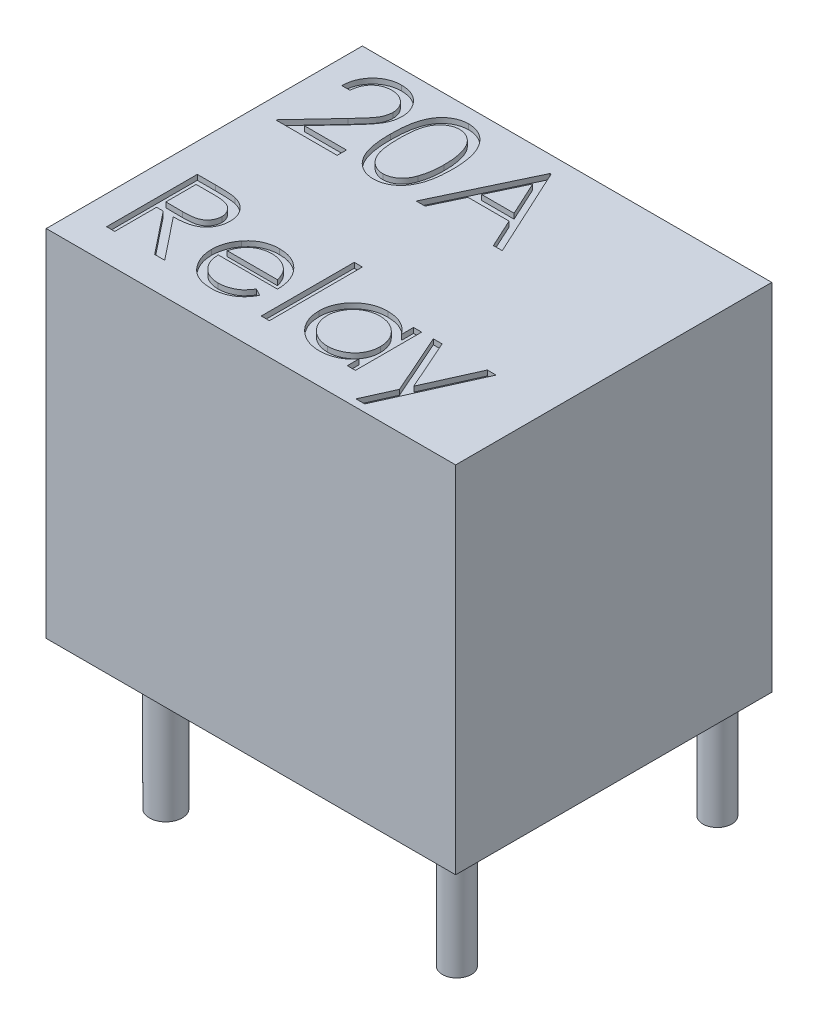
from build123d import *

# Parameters (mm, degrees)
SKETCH1_W           = 15.8
SKETCH1_H           = 12.2
BOSS_EXTRUDE1_DEPTH = 13.7
SKETCH2_W           = 0.314102564
SKETCH2_H           = 3.58974359
CUT_EXTRUDE1_DEPTH  = 0.2
SKETCH3_R           = 0.561179854
SKETCH3_R_2         = 0.557721781
SKETCH3_R_3         = 0.672705982
SKETCH3_R_4         = 0.631160772
SKETCH3_R_5         = 0.616326893
BOSS_EXTRUDE2_DEPTH = 4.2
SKETCH4_W           = 0.531781233
SKETCH4_H           = 8.404737531
BOSS_EXTRUDE3_DEPTH = 0.2


with BuildPart() as part:
    # Sketch1 → Boss-Extrude1 (new body)
    with BuildSketch(Plane(origin=(0, 0, 0), x_dir=(1, 0, 0), z_dir=(0, 1, 0))):
        with Locations((2.206117021, -2.696276596)):
            Rectangle(SKETCH1_W, SKETCH1_H)
    extrude(amount=BOSS_EXTRUDE1_DEPTH)

    # Sketch2 → Cut-Extrude1 (cut)
    with BuildSketch(Plane(origin=(0, 13.7, 0), x_dir=(1, 0, 0), z_dir=(0, 1, 0))):
        with BuildLine():
            Line((-4.454447656, 1.685311696), (-4.76855022, 1.685311696))
            add(Edge.make_bspline(
                [(-4.76855022, 1.685311696), (-4.766503067, 1.726982584), (-4.762482513, 1.808823099), (-4.743654224, 1.928147005), (-4.716713346, 2.042201804), (-4.678621892, 2.150071718), (-4.631315615, 2.252710525), (-4.574585587, 2.349710541), (-4.507391737, 2.440701729), (-4.431185003, 2.524840573), (-4.348416364, 2.602028143), (-4.259110424, 2.668683386), (-4.165265397, 2.725001058), (-4.067165998, 2.772082299), (-3.963705434, 2.807422145), (-3.855822576, 2.833643785), (-3.74304344, 2.849420131), (-3.666203418, 2.851115916), (-3.627123938, 2.851978363)],
                knots=[0, 0, 0, 0, 0.000125083, 0.00024566, 0.000361805, 0.000476223, 0.000588214, 0.000700404, 0.000812728, 0.00092691, 0.001040529, 0.001151727, 0.001260545, 0.001368429, 0.001477521, 0.001587884, 0.001701119, 0.00181831, 0.00181831, 0.00181831, 0.00181831], degree=3))
            add(Edge.make_bspline(
                [(-3.627123938, 2.851978363), (-3.588745864, 2.851079907), (-3.513334319, 2.849314472), (-3.403272305, 2.834153442), (-3.29849501, 2.810407851), (-3.199207244, 2.777092434), (-3.106201179, 2.732308007), (-3.018778135, 2.678510468), (-2.935897324, 2.616290637), (-2.86129054, 2.543036824), (-2.792782461, 2.464834439), (-2.733680206, 2.381346536), (-2.683067042, 2.29511725), (-2.640879362, 2.205489048), (-2.609823223, 2.11161802), (-2.586245015, 2.014870817), (-2.572917602, 1.914246006), (-2.570872178, 1.84613945), (-2.569832271, 1.811513619)],
                knots=[0, 0, 0, 0, 0.000115089, 0.000226145, 0.000332614, 0.000437044, 0.000539592, 0.000641561, 0.000744629, 0.00084975, 0.000954621, 0.001056175, 0.001156101, 0.001254284, 0.001352726, 0.001452208, 0.001552655, 0.001656537, 0.001656537, 0.001656537, 0.001656537], degree=3))
            add(Edge.make_bspline(
                [(-2.569832271, 1.811513619), (-2.571525534, 1.762765785), (-2.574882345, 1.666125571), (-2.603596722, 1.524110708), (-2.648443233, 1.386517289), (-2.70244059, 1.275779987), (-2.756913034, 1.186546493), (-2.806000542, 1.113077789), (-2.863465353, 1.03397232), (-2.930143851, 0.949494983), (-3.004656723, 0.858984078), (-3.087678886, 0.762494282), (-3.179802368, 0.661022512), (-3.244460869, 0.591716911), (-3.277965284, 0.555804485)],
                knots=[0, 0, 0, 0, 0.000146118, 0.000289672, 0.0004329, 0.00057934, 0.000657978, 0.000746456, 0.000844345, 0.000951219, 0.001069268, 0.00119604, 0.001333047, 0.001480391, 0.001480391, 0.001480391, 0.001480391], degree=3))
            Line((-3.277965284, 0.555804485), (-4.153666406, -0.378790868))
            Line((-4.153666406, -0.378790868), (-2.524960476, -0.378790868))
            Line((-2.524960476, -0.378790868), (-2.524960476, -0.737765227))
            Line((-2.524960476, -0.737765227), (-4.903165604, -0.737765227))
            Line((-4.903165604, -0.737765227), (-3.54579381, 0.710752401))
            add(Edge.make_bspline(
                [(-3.54579381, 0.710752401), (-3.512745923, 0.745250708), (-3.449267696, 0.811514895), (-3.359485119, 0.908257855), (-3.278846131, 0.998007395), (-3.206828738, 1.080593944), (-3.144995232, 1.157225512), (-3.090123, 1.225420215), (-3.046157409, 1.288174666), (-2.998442014, 1.36091528), (-2.952228032, 1.449727597), (-2.912515676, 1.558261286), (-2.888300828, 1.669988539), (-2.885395992, 1.745490576), (-2.883934835, 1.783468748)],
                knots=[0, 0, 0, 0, 0.000143319, 0.000275286, 0.00039593, 0.000505287, 0.000603949, 0.000691331, 0.000767782, 0.00083371, 0.000952247, 0.001067137, 0.001179618, 0.001293462, 0.001293462, 0.001293462, 0.001293462], degree=3))
            add(Edge.make_bspline(
                [(-2.883934835, 1.783468748), (-2.884570578, 1.807350146), (-2.885823504, 1.854415796), (-2.896881201, 1.923421555), (-2.913591707, 1.989986369), (-2.937536965, 2.054314988), (-2.969143705, 2.11576064), (-3.007617085, 2.174398121), (-3.052007149, 2.231087086), (-3.103358418, 2.284240384), (-3.159769938, 2.332921589), (-3.219364187, 2.376045675), (-3.282414292, 2.412084786), (-3.348654414, 2.441628283), (-3.417899883, 2.464803664), (-3.490284628, 2.480862243), (-3.565608645, 2.490944727), (-3.61704214, 2.492308899), (-3.643249739, 2.493004004)],
                knots=[0, 0, 0, 0, 7.16e-05, 0.00014111, 0.00020913, 0.00027724, 0.000346538, 0.000415963, 0.000487357, 0.000562233, 0.000637292, 0.000710646, 0.000782564, 0.000854749, 0.000927915, 0.001001225, 0.001076884, 0.001155488, 0.001155488, 0.001155488, 0.001155488], degree=3))
            add(Edge.make_bspline(
                [(-3.643249739, 2.493004004), (-3.670620572, 2.492288972), (-3.724372368, 2.490884766), (-3.803291401, 2.481062102), (-3.878577179, 2.464116262), (-3.950419081, 2.440939588), (-4.018938667, 2.411481039), (-4.083802711, 2.374789294), (-4.144865601, 2.331005801), (-4.202242124, 2.281365245), (-4.255106103, 2.226097643), (-4.301552979, 2.16448768), (-4.342136993, 2.097660265), (-4.377546226, 2.025795714), (-4.406301917, 1.948241934), (-4.428275067, 1.86527423), (-4.445661914, 1.777252848), (-4.451470434, 1.716467763), (-4.454447656, 1.685311696)],
                knots=[0, 0, 0, 0, 8.2106e-05, 0.000161243, 0.000238127, 0.000313291, 0.000387401, 0.000461495, 0.000536397, 0.000612445, 0.000688819, 0.000765383, 0.000843422, 0.000923066, 0.001005373, 0.001091093, 0.001180334, 0.001274175, 0.001274175, 0.001274175, 0.001274175], degree=3))
        make_face()
        with BuildLine():
            add(Edge.make_bspline(
                [(-2.210857912, 1.01083253), (-2.210529894, 1.066929917), (-2.209892714, 1.175899902), (-2.202804293, 1.334684544), (-2.191028951, 1.483644833), (-2.174891578, 1.622787899), (-2.155253598, 1.752149663), (-2.129038111, 1.87138442), (-2.099225308, 1.981044027), (-2.064672863, 2.081486075), (-2.025685074, 2.174063778), (-1.983250813, 2.26048898), (-1.935686018, 2.340630912), (-1.885709106, 2.415768703), (-1.831297034, 2.484672397), (-1.773998243, 2.54831506), (-1.711576367, 2.60522581), (-1.646153359, 2.657072113), (-1.577136895, 2.702521584), (-1.506494228, 2.742554323), (-1.433739123, 2.77675419), (-1.35867294, 2.803644626), (-1.281970382, 2.825855473), (-1.203363315, 2.841044421), (-1.122721951, 2.850601329), (-1.068290516, 2.851514997), (-1.040685637, 2.851978363)],
                knots=[0, 0, 0, 0, 0.000168282, 0.000326891, 0.000476705, 0.00061646, 0.000747059, 0.00086904, 0.000982494, 0.001087814, 0.001187428, 0.001283689, 0.001376399, 0.001466822, 0.001554203, 0.001639568, 0.001723424, 0.001807301, 0.001889751, 0.001971063, 0.002050735, 0.002130583, 0.002210036, 0.002290062, 0.002370508, 0.002453288, 0.002453288, 0.002453288, 0.002453288], degree=3))
            add(Edge.make_bspline(
                [(-1.040685637, 2.851978363), (-1.012850158, 2.851490548), (-0.957494149, 2.850520437), (-0.875653774, 2.841196494), (-0.795704092, 2.825725371), (-0.717985953, 2.803804397), (-0.641860967, 2.77660872), (-0.567924559, 2.742521603), (-0.495717478, 2.702842736), (-0.42638719, 2.656218858), (-0.359172575, 2.604236582), (-0.295724612, 2.545473913), (-0.236037526, 2.480524194), (-0.179362221, 2.41008233), (-0.127306623, 2.332797245), (-0.077733191, 2.250013135), (-0.033361155, 2.160282271), (0.00937352, 2.065101803), (0.046260507, 1.961838144), (0.079526752, 1.851073383), (0.10640572, 1.731499197), (0.128794993, 1.603742951), (0.146139889, 1.467335468), (0.158772531, 1.322569153), (0.165445616, 1.169348762), (0.166702317, 1.064590913), (0.167347216, 1.01083253)],
                knots=[0, 0, 0, 0, 8.3481e-05, 0.000166017, 0.000246731, 0.000327534, 0.000408041, 0.000488986, 0.000571522, 0.000654944, 0.000739373, 0.000826202, 0.000914021, 0.001003809, 0.001097153, 0.001193347, 0.001293057, 0.001397277, 0.001506176, 0.001621751, 0.001744038, 0.001873599, 0.002010742, 0.002156422, 0.002309427, 0.002470709, 0.002470709, 0.002470709, 0.002470709], degree=3))
            add(Edge.make_bspline(
                [(0.167347216, 1.01083253), (0.166695631, 0.957308622), (0.165426046, 0.85301947), (0.158847339, 0.700488495), (0.145888708, 0.556490451), (0.129678719, 0.420679989), (0.107227756, 0.29362237), (0.07962259, 0.174877921), (0.048972267, 0.06393385), (0.011137473, -0.038300962), (-0.030273237, -0.133252685), (-0.075328433, -0.221919833), (-0.123598259, -0.305086126), (-0.176187004, -0.382085873), (-0.232240418, -0.45346453), (-0.292958206, -0.517962152), (-0.356628792, -0.577132824), (-0.424041207, -0.629784452), (-0.494452759, -0.675869256), (-0.566411836, -0.717083107), (-0.641195219, -0.750315802), (-0.717108172, -0.778850843), (-0.795236538, -0.800651295), (-0.875482928, -0.81572515), (-0.957439164, -0.826296999), (-1.012840729, -0.827103479), (-1.040685637, -0.827508817)],
                knots=[0, 0, 0, 0, 0.000160581, 0.000312886, 0.000457868, 0.000594226, 0.000723097, 0.000844701, 0.000959884, 0.001068125, 0.001171421, 0.001270505, 0.001366343, 0.001459687, 0.001550023, 0.00163832, 0.001725149, 0.001810562, 0.001894568, 0.001977446, 0.00205903, 0.002139777, 0.00222058, 0.002301983, 0.002384599, 0.00246808, 0.00246808, 0.00246808, 0.00246808], degree=3))
            add(Edge.make_bspline(
                [(-1.040685637, -0.827508817), (-1.068289751, -0.827042461), (-1.122719675, -0.826122899), (-1.203372101, -0.816609168), (-1.281654544, -0.801313664), (-1.357953298, -0.77989706), (-1.432659813, -0.753682224), (-1.5047561, -0.71952854), (-1.575043784, -0.680194471), (-1.64333534, -0.63539905), (-1.708347501, -0.584077367), (-1.770446106, -0.527313078), (-1.828071125, -0.463689667), (-1.881705221, -0.394211744), (-1.932679309, -0.319518501), (-1.979568682, -0.238590128), (-2.022939536, -0.151747518), (-2.062583027, -0.058429607), (-2.09773169, 0.042725321), (-2.128779399, 0.152874499), (-2.153293556, 0.272990135), (-2.174276511, 0.402107502), (-2.191200894, 0.540781433), (-2.20275522, 0.689087211), (-2.209896535, 0.84693242), (-2.210531605, 0.955202194), (-2.210857912, 1.01083253)],
                knots=[0, 0, 0, 0, 8.278e-05, 0.000163226, 0.000243252, 0.00032184, 0.00040079, 0.000480463, 0.00056082, 0.000642298, 0.000725191, 0.000809047, 0.000894412, 0.000982346, 0.001072188, 0.001165503, 0.001262704, 0.001363236, 0.001469448, 0.001583766, 0.001706286, 0.001836995, 0.001976138, 0.002125253, 0.002283161, 0.002450041, 0.002450041, 0.002450041, 0.002450041], degree=3))
        make_face()
        with BuildLine():
            add(Edge.make_bspline(
                [(-1.896755348, 1.012234773), (-1.896635901, 0.965486074), (-1.896404078, 0.87475603), (-1.890347877, 0.742912769), (-1.882097645, 0.61994244), (-1.871456348, 0.505688903), (-1.855653399, 0.400538891), (-1.837946612, 0.303769208), (-1.816398522, 0.215891971), (-1.790903504, 0.13630416), (-1.761864407, 0.063655091), (-1.730158544, -0.003946124), (-1.696097821, -0.06729806), (-1.65797867, -0.125831668), (-1.616463607, -0.179737833), (-1.572490348, -0.229970665), (-1.524417763, -0.274767646), (-1.457914021, -0.328494501), (-1.370117547, -0.384013635), (-1.259497091, -0.432359725), (-1.14582864, -0.462742181), (-1.06867739, -0.466605937), (-1.03016881, -0.468534458)],
                knots=[0, 0, 0, 0, 0.000140231, 0.000272162, 0.000395845, 0.00050998, 0.000616273, 0.00071473, 0.000805025, 0.000887508, 0.000965234, 0.00103957, 0.001111417, 0.001180842, 0.001248855, 0.001315406, 0.001380877, 0.0014457, 0.001571746, 0.00169106, 0.001806864, 0.001922266, 0.001922266, 0.001922266, 0.001922266], degree=3))
            add(Edge.make_bspline(
                [(-1.03016881, -0.468534458), (-0.991411138, -0.466936677), (-0.913975815, -0.463744414), (-0.80084202, -0.432945677), (-0.69101175, -0.386476137), (-0.604939809, -0.331528632), (-0.539457266, -0.279200302), (-0.492540276, -0.234585654), (-0.449478227, -0.184629787), (-0.408636152, -0.130730491), (-0.371177077, -0.071858007), (-0.337113939, -0.008295431), (-0.306030591, 0.060133747), (-0.288321546, 0.107903486), (-0.279267367, 0.132326921)],
                knots=[0, 0, 0, 0, 0.000116044, 0.000231848, 0.000349318, 0.000472837, 0.000536674, 0.000600645, 0.000666733, 0.000734322, 0.000803367, 0.000875831, 0.000950509, 0.001028633, 0.001028633, 0.001028633, 0.001028633], degree=3))
            add(Edge.make_bspline(
                [(-0.279267367, 0.132326921), (-0.2687156, 0.16355666), (-0.247290986, 0.226966424), (-0.219679211, 0.325330076), (-0.197933812, 0.42853284), (-0.178370446, 0.535957957), (-0.165017391, 0.648397658), (-0.154269577, 0.765504042), (-0.14793889, 0.887365404), (-0.147154139, 0.970160395), (-0.146755348, 1.012234773)],
                knots=[0, 0, 0, 0, 9.8886e-05, 0.00020078, 0.000306259, 0.000415188, 0.00052824, 0.000645799, 0.000767957, 0.000894177, 0.000894177, 0.000894177, 0.000894177], degree=3))
            add(Edge.make_bspline(
                [(-0.146755348, 1.012234773), (-0.147305537, 1.054302346), (-0.148381825, 1.136595511), (-0.152495813, 1.257113691), (-0.163119387, 1.371581452), (-0.174918506, 1.480491925), (-0.192315727, 1.583242227), (-0.211073534, 1.680692533), (-0.236274746, 1.771635558), (-0.263194521, 1.857495139), (-0.294004917, 1.937295794), (-0.327920651, 2.01140958), (-0.36414241, 2.080194305), (-0.40348465, 2.143461246), (-0.445480333, 2.201493789), (-0.491237883, 2.253128384), (-0.538942255, 2.299965352), (-0.605759441, 2.353427921), (-0.693233731, 2.407939617), (-0.802079378, 2.458105376), (-0.915350023, 2.486913669), (-0.991923477, 2.490975356), (-1.03016881, 2.493004004)],
                knots=[0, 0, 0, 0, 0.000126219, 0.000246912, 0.000361616, 0.00047102, 0.00057545, 0.000674176, 0.000768567, 0.000858368, 0.000944043, 0.001024988, 0.001102772, 0.001177091, 0.00124833, 0.001317386, 0.001383826, 0.001448649, 0.001573728, 0.001692043, 0.001806995, 0.001921698, 0.001921698, 0.001921698, 0.001921698], degree=3))
            add(Edge.make_bspline(
                [(-1.03016881, 2.493004004), (-1.068879402, 2.490972557), (-1.146371107, 2.486905963), (-1.260819062, 2.45821271), (-1.370523414, 2.408199744), (-1.457766388, 2.353247371), (-1.524630175, 2.30090906), (-1.571712868, 2.255522606), (-1.61585904, 2.205876351), (-1.656526741, 2.151474437), (-1.694616024, 2.093009069), (-1.729597036, 2.030020304), (-1.761114366, 1.96218894), (-1.790198902, 1.889572505), (-1.81577169, 1.80999156), (-1.836865653, 1.722222567), (-1.856352707, 1.625760675), (-1.870147975, 1.520041167), (-1.882411731, 1.405759014), (-1.890293079, 1.282481695), (-1.896424337, 1.150417315), (-1.896642801, 1.059218157), (-1.896755348, 1.012234773)],
                knots=[0, 0, 0, 0, 0.000116101, 0.000232413, 0.000351368, 0.000476447, 0.000540832, 0.000605795, 0.000672346, 0.000739935, 0.00080936, 0.000881545, 0.00095588, 0.001033607, 0.001116089, 0.001206384, 0.001304286, 0.001411174, 0.001526077, 0.001649061, 0.001781692, 0.001922624, 0.001922624, 0.001922624, 0.001922624], degree=3))
        make_face(mode=Mode.SUBTRACT)
        Polygon((2.23144978, 2.762234773), (3.846834396, -0.737765227), (3.505388081, -0.737765227), (2.987960197, 0.384029645), (1.401321575, 0.384029645), (0.869170133, -0.737765227), (0.526321575, -0.737765227), (2.186577985, 2.762234773), align=None)
        Polygon((2.205508274, 2.080043267), (1.571694171, 0.743004004), (2.822495453, 0.743004004), align=None, mode=Mode.SUBTRACT)
        with BuildLine():
            Line((-4.58906304, -4.07109856), (-3.888642367, -4.07109856))
            add(Edge.make_bspline(
                [(-3.888642367, -4.07109856), (-3.841901239, -4.071254146), (-3.752153094, -4.071552888), (-3.623579824, -4.073218651), (-3.506752727, -4.077993007), (-3.401732888, -4.082101591), (-3.308522233, -4.089593532), (-3.226834942, -4.096754179), (-3.157047244, -4.10612784), (-3.114801393, -4.114833263), (-3.095673617, -4.118774842)],
                knots=[0, 0, 0, 0, 0.000140226, 0.00026925, 0.000385712, 0.000490995, 0.000584507, 0.000666202, 0.000736998, 0.000795574, 0.000795574, 0.000795574, 0.000795574], degree=3))
            add(Edge.make_bspline(
                [(-3.095673617, -4.118774842), (-3.070066993, -4.125101608), (-3.019400004, -4.137620171), (-2.946449938, -4.164079772), (-2.876935614, -4.194699397), (-2.811145789, -4.230663117), (-2.749409998, -4.272237897), (-2.691091687, -4.318706019), (-2.635926224, -4.369813225), (-2.586144594, -4.426848066), (-2.539205542, -4.486684576), (-2.499616916, -4.551388333), (-2.465490436, -4.61904986), (-2.438319919, -4.690357278), (-2.416441945, -4.76461905), (-2.401015706, -4.842507847), (-2.391764518, -4.923668822), (-2.390822663, -4.979026731), (-2.390345092, -5.007096156)],
                knots=[0, 0, 0, 0, 7.9081e-05, 0.000156475, 0.000232432, 0.000306798, 0.00038108, 0.000455429, 0.000530331, 0.000606314, 0.000682321, 0.000758201, 0.000833453, 0.000909362, 0.000986794, 0.001065445, 0.001147284, 0.001231465, 0.001231465, 0.001231465, 0.001231465], degree=3))
            add(Edge.make_bspline(
                [(-2.390345092, -5.007096156), (-2.39181409, -5.053731261), (-2.394680486, -5.144728429), (-2.421405589, -5.27678931), (-2.465182109, -5.399978625), (-2.525505398, -5.514141263), (-2.602324874, -5.617051908), (-2.694649665, -5.707442363), (-2.802531276, -5.783082276), (-2.902960592, -5.835535081), (-2.991674792, -5.869127989), (-3.064708105, -5.892764348), (-3.144375082, -5.911026313), (-3.229912417, -5.927386445), (-3.321676072, -5.93973814), (-3.419446112, -5.948784734), (-3.523292263, -5.954438783), (-3.594631333, -5.955280788), (-3.631330669, -5.955713945)],
                knots=[0, 0, 0, 0, 0.000139777, 0.000272741, 0.000402249, 0.000530843, 0.000658588, 0.000786009, 0.000916741, 0.001052522, 0.001124656, 0.001201155, 0.001282612, 0.001369656, 0.001462366, 0.001560247, 0.001664165, 0.001774261, 0.001774261, 0.001774261, 0.001774261], degree=3))
            Line((-3.631330669, -5.955713945), (-2.345473297, -7.57109856))
            Line((-2.345473297, -7.57109856), (-2.733894771, -7.57109856))
            Line((-2.733894771, -7.57109856), (-4.019752143, -5.955713945))
            Line((-4.019752143, -5.955713945), (-4.274960476, -5.955713945))
            Line((-4.274960476, -5.955713945), (-4.274960476, -7.57109856))
            Line((-4.274960476, -7.57109856), (-4.58906304, -7.57109856))
            Line((-4.58906304, -7.57109856), (-4.58906304, -4.07109856))
        make_face()
        with BuildLine():
            Line((-4.274960476, -4.430072919), (-4.274960476, -5.596739586))
            Line((-4.274960476, -5.596739586), (-3.634135156, -5.601647438))
            add(Edge.make_bspline(
                [(-3.634135156, -5.601647438), (-3.604215117, -5.601660675), (-3.54622156, -5.601686331), (-3.462320895, -5.597692555), (-3.384200783, -5.593149237), (-3.312160031, -5.586199891), (-3.246166456, -5.57724382), (-3.186253043, -5.566040835), (-3.132321991, -5.552988773), (-3.069423452, -5.532787147), (-2.999186921, -5.500781129), (-2.922855461, -5.45421563), (-2.857853123, -5.395646511), (-2.802935261, -5.328673055), (-2.758805829, -5.255036806), (-2.727693775, -5.175620437), (-2.707951333, -5.092428839), (-2.705622787, -5.035250731), (-2.704447656, -5.006395034)],
                knots=[0, 0, 0, 0, 8.9746e-05, 0.000173954, 0.000251933, 0.000324488, 0.000391021, 0.000451663, 0.000507268, 0.000557378, 0.000649639, 0.000738152, 0.000824558, 0.000910739, 0.000997194, 0.001080909, 0.00116578, 0.001252248, 0.001252248, 0.001252248, 0.001252248], degree=3))
            add(Edge.make_bspline(
                [(-2.704447656, -5.006395034), (-2.705649777, -4.978248461), (-2.708031942, -4.922472222), (-2.727480711, -4.840816312), (-2.760370092, -4.763749362), (-2.80469233, -4.691584877), (-2.858691485, -4.626079141), (-2.922009298, -4.570031988), (-2.992914493, -4.523782523), (-3.059185691, -4.494228143), (-3.118419904, -4.476108289), (-3.169849564, -4.463357125), (-3.227961041, -4.453112657), (-3.2930365, -4.444904596), (-3.364798131, -4.437849651), (-3.443608782, -4.433097873), (-3.528945562, -4.430284009), (-3.588092493, -4.43014492), (-3.618710476, -4.430072919)],
                knots=[0, 0, 0, 0, 8.4371e-05, 0.000167192, 0.000250141, 0.000334794, 0.000420435, 0.000503871, 0.000587493, 0.000673488, 0.0007205, 0.000773215, 0.000832351, 0.0008974, 0.000969955, 0.001048634, 0.001134217, 0.001226067, 0.001226067, 0.001226067, 0.001226067], degree=3))
            Line((-3.618710476, -4.430072919), (-4.274960476, -4.430072919))
        make_face(mode=Mode.SUBTRACT)
        with BuildLine():
            Line((0.381890485, -6.763406252), (0.66093696, -6.909940708))
            add(Edge.make_bspline(
                [(0.66093696, -6.909940708), (0.638700364, -6.949384039), (0.595436756, -7.026125142), (0.521036008, -7.131557002), (0.443043935, -7.226404718), (0.357939967, -7.308134372), (0.268270288, -7.379385757), (0.173537634, -7.441723582), (0.073248816, -7.494842102), (-0.032600909, -7.53959463), (-0.14490046, -7.574004124), (-0.263921976, -7.598308345), (-0.389893472, -7.613331614), (-0.476239652, -7.615076755), (-0.520453265, -7.615970355)],
                knots=[0, 0, 0, 0, 0.000135759, 0.000264133, 0.000386579, 0.000503597, 0.000617365, 0.000729763, 0.000843304, 0.000957371, 0.001074023, 0.001195027, 0.001321389, 0.001453992, 0.001453992, 0.001453992, 0.001453992], degree=3))
            add(Edge.make_bspline(
                [(-0.520453265, -7.615970355), (-0.569595242, -7.61482318), (-0.665457004, -7.612585373), (-0.804996751, -7.593292908), (-0.936376169, -7.56182055), (-1.059587873, -7.517855008), (-1.174330125, -7.460427684), (-1.28083098, -7.390468202), (-1.379650506, -7.308335948), (-1.467674715, -7.213319504), (-1.546918598, -7.111637547), (-1.616844418, -7.005681662), (-1.675301849, -6.895718438), (-1.722854459, -6.782447914), (-1.761259324, -6.66658402), (-1.788026028, -6.547072553), (-1.803455776, -6.424236969), (-1.805820221, -6.341139633), (-1.807011758, -6.299263624)],
                knots=[0, 0, 0, 0, 0.000147371, 0.000287478, 0.000421649, 0.000552053, 0.000679042, 0.000805636, 0.000933558, 0.00106351, 0.001193382, 0.001319977, 0.001443869, 0.001566405, 0.001688128, 0.001809576, 0.001933238, 0.002058864, 0.002058864, 0.002058864, 0.002058864], degree=3))
            add(Edge.make_bspline(
                [(-1.807011758, -6.299263624), (-1.805952617, -6.259968794), (-1.803853539, -6.182091629), (-1.790622751, -6.066826085), (-1.767174458, -5.954797632), (-1.734998134, -5.845913184), (-1.693446888, -5.74035505), (-1.642614669, -5.638058986), (-1.582422291, -5.539133847), (-1.535949617, -5.476730713), (-1.512540604, -5.445297278)],
                knots=[0, 0, 0, 0, 0.000117891, 0.000233644, 0.000347498, 0.000460856, 0.000573868, 0.000687374, 0.000803169, 0.000920699, 0.000920699, 0.000920699, 0.000920699], degree=3))
            add(Edge.make_bspline(
                [(-1.512540604, -5.445297278), (-1.480832922, -5.407428408), (-1.418421975, -5.332890258), (-1.31286562, -5.234951932), (-1.198565423, -5.152908157), (-1.076953797, -5.08490102), (-0.946617323, -5.033227373), (-0.809308032, -4.994719791), (-0.663462446, -4.97314178), (-0.563757225, -4.970093947), (-0.512740925, -4.968534458)],
                knots=[0, 0, 0, 0, 0.000148071, 0.000291452, 0.00043058, 0.000569298, 0.000708346, 0.00085021, 0.000996268, 0.001149307, 0.001149307, 0.001149307, 0.001149307], degree=3))
            add(Edge.make_bspline(
                [(-0.512740925, -4.968534458), (-0.46029332, -4.969888506), (-0.357403074, -4.972544842), (-0.207370953, -4.997171175), (-0.065410236, -5.03622373), (0.068422268, -5.09137752), (0.194140129, -5.162537072), (0.310926178, -5.250678913), (0.420777691, -5.353097001), (0.48468627, -5.43186021), (0.517206992, -5.471939906)],
                knots=[0, 0, 0, 0, 0.000157241, 0.00030847, 0.000454763, 0.000598116, 0.000741606, 0.000886879, 0.001036172, 0.001190853, 0.001190853, 0.001190853, 0.001190853], degree=3))
            add(Edge.make_bspline(
                [(0.517206992, -5.471939906), (0.53933393, -5.502143488), (0.583440523, -5.562349606), (0.638687623, -5.660520763), (0.686645018, -5.763231358), (0.724977979, -5.872141655), (0.75601748, -5.985961235), (0.778474299, -6.10550378), (0.791643918, -6.230733691), (0.794232615, -6.316060247), (0.795552344, -6.359560099)],
                knots=[0, 0, 0, 0, 0.000112234, 0.000223721, 0.000337279, 0.000451932, 0.000569628, 0.000690912, 0.000816421, 0.00094695, 0.00094695, 0.00094695, 0.00094695], degree=3))
            Line((0.795552344, -6.359560099), (-1.492909194, -6.359560099))
            add(Edge.make_bspline(
                [(-1.492909194, -6.359560099), (-1.491369588, -6.393260563), (-1.488342014, -6.459531167), (-1.474226871, -6.55650195), (-1.451978097, -6.648875292), (-1.420709034, -6.735958334), (-1.382842189, -6.818888461), (-1.336456472, -6.897050498), (-1.281116918, -6.970088428), (-1.219391219, -7.038655566), (-1.150684124, -7.099716327), (-1.078401376, -7.154368103), (-1.001507811, -7.2001737), (-0.920609728, -7.23735359), (-0.835837943, -7.266459906), (-0.747165748, -7.286327727), (-0.654767631, -7.299634833), (-0.591781897, -7.301114499), (-0.559716085, -7.301867791)],
                knots=[0, 0, 0, 0, 0.000101159, 0.000198924, 0.000293472, 0.000385722, 0.000476069, 0.000566611, 0.000657757, 0.000750573, 0.000842919, 0.000933083, 0.001022062, 0.001110842, 0.001199752, 0.001290403, 0.001383113, 0.001479259, 0.001479259, 0.001479259, 0.001479259], degree=3))
            add(Edge.make_bspline(
                [(-0.559716085, -7.301867791), (-0.528364938, -7.301259734), (-0.466158247, -7.300053233), (-0.373517389, -7.288321322), (-0.282377862, -7.269351047), (-0.193116879, -7.243461057), (-0.107546033, -7.211884204), (-0.028300483, -7.173781347), (0.044579733, -7.1316316), (0.112696699, -7.083421925), (0.178767693, -7.024413738), (0.244310179, -6.950778017), (0.314586833, -6.863690489), (0.358576425, -6.798144823), (0.381890485, -6.763406252)],
                knots=[0, 0, 0, 0, 9.4016e-05, 0.000186545, 0.000279636, 0.000373054, 0.000465125, 0.000552934, 0.000636508, 0.000717442, 0.000802858, 0.000901616, 0.001012865, 0.001138311, 0.001138311, 0.001138311, 0.001138311], degree=3))
        make_face()
        with BuildLine():
            add(Edge.make_bspline(
                [(0.48144978, -6.045457534), (0.469953156, -6.003794661), (0.447825854, -5.92360704), (0.40158949, -5.81256615), (0.349517949, -5.713878249), (0.287896218, -5.628298616), (0.218077492, -5.552295103), (0.137432309, -5.485876518), (0.046996416, -5.426459066), (-0.052762725, -5.376306567), (-0.15840451, -5.333616708), (-0.269010702, -5.304991593), (-0.38186849, -5.28538205), (-0.458202776, -5.283555942), (-0.496615124, -5.282637022)],
                knots=[0, 0, 0, 0, 0.000129543, 0.000249328, 0.000360065, 0.000463575, 0.000564789, 0.000668832, 0.000776175, 0.000888744, 0.001003316, 0.001117263, 0.001230914, 0.001346035, 0.001346035, 0.001346035, 0.001346035], degree=3))
            add(Edge.make_bspline(
                [(-0.496615124, -5.282637022), (-0.527964562, -5.283248693), (-0.589935811, -5.284457839), (-0.681236879, -5.295927969), (-0.768916578, -5.314887813), (-0.853621866, -5.34085277), (-0.934242734, -5.375461373), (-1.012437503, -5.416044599), (-1.086217899, -5.465586183), (-1.132359194, -5.503345038), (-1.155669611, -5.522420675)],
                knots=[0, 0, 0, 0, 9.4016e-05, 0.000185849, 0.000275511, 0.000362884, 0.000451173, 0.00053836, 0.000626838, 0.000717174, 0.000717174, 0.000717174, 0.000717174], degree=3))
            add(Edge.make_bspline(
                [(-1.155669611, -5.522420675), (-1.172362893, -5.537514991), (-1.206146027, -5.568062207), (-1.251286549, -5.620691414), (-1.294507021, -5.677442976), (-1.333840674, -5.7404881), (-1.36991826, -5.809108879), (-1.403678238, -5.882726515), (-1.43406465, -5.961899645), (-1.45116076, -6.017072084), (-1.45995647, -6.045457534)],
                knots=[0, 0, 0, 0, 6.7454e-05, 0.00013651, 0.000207604, 0.000281328, 0.000359112, 0.000440057, 0.000524171, 0.000613305, 0.000613305, 0.000613305, 0.000613305], degree=3))
            Line((-1.45995647, -6.045457534), (0.48144978, -6.045457534))
        make_face(mode=Mode.SUBTRACT)
        with Locations((1.53593696, -5.776226765)):
            Rectangle(SKETCH2_W, SKETCH2_H)
        with BuildLine():
            Line((5.013501062, -5.013406252), (5.013501062, -7.57109856))
            Line((5.013501062, -7.57109856), (4.699398498, -7.57109856))
            Line((4.699398498, -7.57109856), (4.699398498, -7.128690708))
            add(Edge.make_bspline(
                [(4.699398498, -7.128690708), (4.663979707, -7.168730302), (4.594859492, -7.246868073), (4.479418374, -7.348950245), (4.357050196, -7.433328567), (4.228348875, -7.501478482), (4.093430632, -7.552670539), (3.952594545, -7.589056698), (3.805783164, -7.612450533), (3.705530809, -7.614786555), (3.654727024, -7.615970355)],
                knots=[0, 0, 0, 0, 0.000160263, 0.000312755, 0.000460949, 0.000605216, 0.000748578, 0.000892786, 0.001041028, 0.001193333, 0.001193333, 0.001193333, 0.001193333], degree=3))
            add(Edge.make_bspline(
                [(3.654727024, -7.615970355), (3.60955907, -7.614743983), (3.520485865, -7.612325522), (3.389456788, -7.593563219), (3.263364538, -7.563432597), (3.142089966, -7.521531708), (3.02641782, -7.465950886), (2.915357724, -7.399409638), (2.809485032, -7.320168808), (2.710413493, -7.229580779), (2.619181492, -7.131185792), (2.53912022, -7.026240245), (2.47236714, -6.915197941), (2.416547059, -6.799464788), (2.373550715, -6.678149868), (2.34357708, -6.5516727), (2.324836634, -6.420182827), (2.322419173, -6.330643303), (2.32119337, -6.285241188)],
                knots=[0, 0, 0, 0, 0.000135464, 0.00026714, 0.000396211, 0.000523931, 0.000651257, 0.000780517, 0.000911767, 0.001047265, 0.00118272, 0.001313831, 0.001442491, 0.001570752, 0.001698704, 0.001827775, 0.001960146, 0.00209631, 0.00209631, 0.00209631, 0.00209631], degree=3))
            add(Edge.make_bspline(
                [(2.32119337, -6.285241188), (2.322446341, -6.240777485), (2.324923398, -6.152875141), (2.343376618, -6.023596443), (2.374407627, -5.899078183), (2.417955474, -5.779721239), (2.473797429, -5.665381189), (2.541725516, -5.555977164), (2.621744641, -5.451207767), (2.713997048, -5.35353654), (2.813931818, -5.263315926), (2.920840549, -5.18490688), (3.03206383, -5.117190032), (3.149326841, -5.063536555), (3.270893946, -5.020127451), (3.397847391, -4.990094483), (3.52965897, -4.972397161), (3.619149462, -4.969834397), (3.664542729, -4.968534458)],
                knots=[0, 0, 0, 0, 0.000133363, 0.00026365, 0.000390846, 0.000517716, 0.000644083, 0.000771912, 0.000903449, 0.001038867, 0.001174416, 0.001306792, 0.001436052, 0.00156435, 0.001692963, 0.001822716, 0.001954992, 0.002091156, 0.002091156, 0.002091156, 0.002091156], degree=3))
            add(Edge.make_bspline(
                [(3.664542729, -4.968534458), (3.716742588, -4.969972209), (3.819104048, -4.972791572), (3.968832057, -4.996254299), (4.110476535, -5.035892766), (4.245130887, -5.089810265), (4.372311573, -5.161458994), (4.490814558, -5.251838955), (4.601880041, -5.360380142), (4.666260332, -5.443750586), (4.699398498, -5.486663464)],
                knots=[0, 0, 0, 0, 0.00015654, 0.000306968, 0.000453261, 0.000596998, 0.000741098, 0.000889738, 0.001042937, 0.001205434, 0.001205434, 0.001205434, 0.001205434], degree=3))
            Line((4.699398498, -5.486663464), (4.699398498, -5.013406252))
            Line((4.699398498, -5.013406252), (5.013501062, -5.013406252))
        make_face()
        with BuildLine():
            add(Edge.make_bspline(
                [(3.66874946, -5.282637022), (3.622835122, -5.284270659), (3.532207522, -5.2874952), (3.39916352, -5.312668696), (3.271850106, -5.35455329), (3.150904031, -5.411835191), (3.038235815, -5.483863928), (2.937542144, -5.570985311), (2.847999443, -5.670822325), (2.772691178, -5.782924436), (2.711300681, -5.903102527), (2.668133649, -6.028726965), (2.639664402, -6.157531942), (2.636755881, -6.244894628), (2.635295934, -6.288746797)],
                knots=[0, 0, 0, 0, 0.000137677, 0.000271753, 0.000404561, 0.000538791, 0.000672205, 0.000804452, 0.00093703, 0.001073348, 0.00120849, 0.001340643, 0.001470999, 0.001602378, 0.001602378, 0.001602378, 0.001602378], degree=3))
            add(Edge.make_bspline(
                [(2.635295934, -6.288746797), (2.637160827, -6.332336904), (2.640883304, -6.41934626), (2.667633999, -6.548326837), (2.712513872, -6.673980879), (2.773755935, -6.795241873), (2.850442559, -6.907825973), (2.939331212, -7.009566096), (3.041281493, -7.097055684), (3.154209, -7.170293257), (3.274816971, -7.229455778), (3.401650902, -7.270621418), (3.53232654, -7.297199199), (3.621178874, -7.300303675), (3.665944972, -7.301867791)],
                knots=[0, 0, 0, 0, 0.000130727, 0.000260941, 0.000393327, 0.000530037, 0.000667328, 0.000800955, 0.000934191, 0.001068956, 0.001203792, 0.001335934, 0.001468075, 0.001602253, 0.001602253, 0.001602253, 0.001602253], degree=3))
            add(Edge.make_bspline(
                [(3.665944972, -7.301867791), (3.711391475, -7.300207827), (3.801780062, -7.296906323), (3.93521877, -7.271625058), (4.064713732, -7.22985626), (4.188500961, -7.171957133), (4.303817092, -7.100199777), (4.40731497, -7.016192686), (4.494830938, -6.918489502), (4.569023547, -6.811113049), (4.627198964, -6.693401052), (4.669575023, -6.568066862), (4.694628929, -6.435106114), (4.697786659, -6.344242187), (4.699398498, -6.297861381)],
                knots=[0, 0, 0, 0, 0.000136278, 0.000271043, 0.000405851, 0.000543552, 0.000679927, 0.000812429, 0.000941985, 0.001072088, 0.00120284, 0.001334538, 0.001467925, 0.001607002, 0.001607002, 0.001607002, 0.001607002], degree=3))
            add(Edge.make_bspline(
                [(4.699398498, -6.297861381), (4.698438842, -6.26252355), (4.696549934, -6.192967517), (4.682119365, -6.090839999), (4.659164438, -5.993106273), (4.626818268, -5.899663584), (4.584326984, -5.811028569), (4.533079218, -5.726564809), (4.472173768, -5.646711597), (4.402591072, -5.572568526), (4.32642587, -5.504942064), (4.245831329, -5.444577823), (4.159852582, -5.39498905), (4.069935545, -5.353947779), (3.975924211, -5.321288629), (3.877053591, -5.299500935), (3.774374604, -5.284540614), (3.704328549, -5.283278233), (3.66874946, -5.282637022)],
                knots=[0, 0, 0, 0, 0.000105983, 0.000208608, 0.000308773, 0.00040678, 0.000504626, 0.000603105, 0.000702667, 0.00080535, 0.000907651, 0.001007914, 0.001106881, 0.00120477, 0.001304102, 0.001404791, 0.00150811, 0.001614764, 0.001614764, 0.001614764, 0.001614764], degree=3))
        make_face(mode=Mode.SUBTRACT)
        Polygon((5.462219011, -5.013406252), (5.800860838, -5.013406252), (6.666746254, -6.972340547), (7.545952985, -5.013406252), (7.885295934, -5.013406252), (6.314783113, -8.513406252), (5.975440165, -8.513406252), (6.496373658, -7.353049682), align=None)
    extrude(amount=-CUT_EXTRUDE1_DEPTH, mode=Mode.SUBTRACT)

    # Sketch3 → Boss-Extrude2 (add)
    with BuildSketch(Plane.XZ):
        with Locations((8.983085169, 7.624980703)):
            Circle(SKETCH3_R)
        with Locations((8.983085169, -2.426981621)):
            Circle(SKETCH3_R_2)
        with Locations((-4.830256606, 3.241028102)):
            Circle(SKETCH3_R_3)
        with Locations((-1.898974689, 7.9751781)):
            Circle(SKETCH3_R_4)
        with Locations((-1.76927195, -2.323219429)):
            Circle(SKETCH3_R_5)
    extrude(amount=BOSS_EXTRUDE2_DEPTH)

    # Sketch4 → Boss-Extrude3 (add)
    with BuildSketch(Plane.XZ):
        with Locations((-1.840608457, 2.825979336)):
            Rectangle(SKETCH4_W, SKETCH4_H)
    extrude(amount=BOSS_EXTRUDE3_DEPTH)


solid = part.part
